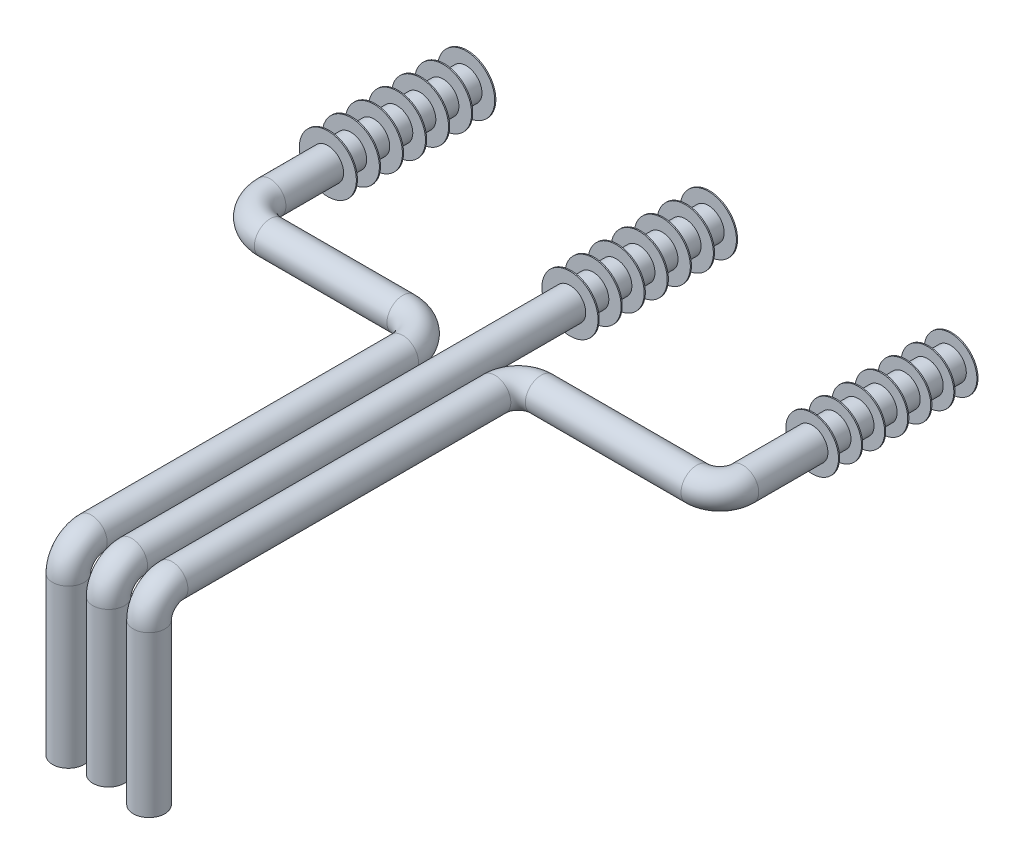
from build123d import *

# Parameters (mm, degrees)
BARRER5_PROFILE_R       = 13.7
BARRER6_PROFILE_R       = 13.7
CROQUIS41_R             = 13.7
CROQUIS62_R             = 22.870183784
CROQUIS62_R_2           = 24.36570856
CROQUIS62_R_3           = 24.738020287
SALIENTE_EXTRUIR1_DEPTH = 1
MATRIZL1_COUNT          = 7
MATRIZL1_PITCH          = 20


with BuildPart() as part:
    # Barrer5: sweep along a curve in space
    with BuildLine() as barrer5_path:
        Line((0, 0, 0), (0, 0, 170))
        ThreePointArc((0, 0, 170), (8.786796564, 0, 191.213203436), (30, 0, 200))
        Line((30, 0, 200), (145.00018, 0, 200))
        ThreePointArc((145.00018, 0, 200), (166.213383436, 0, 208.786796564), (175.00018, 0, 230))
        Line((175.00018, 0, 230), (175.00018, 0, 500))
        ThreePointArc((175.00018, 0, 500), (175.00018, -5.857864376, 514.142135624), (175.00018, -20, 520))
        Line((175.00018, -20, 520), (175.00018, -156.800061359, 520))
    # Barrer5 profile (on start of the path) → Barrer5 (sweep)
    with BuildSketch(Plane.XY):
        Circle(BARRER5_PROFILE_R)
    sweep(path=barrer5_path.line)


with BuildPart() as body_2:
    # Barrer6: sweep along a curve in space
    with BuildLine() as barrer6_path:
        Line((210, 0, 0), (210, 0, 499.997033))
        ThreePointArc((210, 0, 499.997033), (210, -5.857864376, 514.139168624), (210, -20, 519.997033))
        Line((210, -20, 519.997033), (210, -153.425324093, 519.997033))
    # Barrer6 profile (on start of the path) → Barrer6 (sweep)
    with BuildSketch(Plane(origin=(210, 0, 0), x_dir=(1, 0, 0), z_dir=(0, 0, 1))):
        Circle(BARRER6_PROFILE_R)
    sweep(path=barrer6_path.line)


with BuildPart() as body_3:
    # Barrer7: sweep along a curve in space
    with BuildLine() as barrer7_path:
        Line((420, 0, 0), (420, 0, 180))
        ThreePointArc((420, 0, 180), (414.142135624, 0, 194.142135624), (400, 0, 200))
        Line((400, 0, 200), (264.998005, 0, 200))
        ThreePointArc((264.998005, 0, 200), (250.855869376, 0, 205.857864376), (244.998005, 0, 220))
        Line((244.998005, 0, 220), (244.998005, 0, 500))
        ThreePointArc((244.998005, 0, 500), (244.998005, -5.857864376, 514.142135624), (244.998005, -20, 520))
        Line((244.998005, -20, 520), (244.998005, -158.814937218, 520))
    # Croquis41 → Barrer7 (sweep)
    with BuildSketch(Plane(origin=(0, 0, 0), x_dir=(-1, 0, 0), z_dir=(0, 0, -1))):
        with Locations((-420, 0)):
            Circle(CROQUIS41_R)
    sweep(path=barrer7_path.line)

    # Croquis62 → Saliente-Extruir1 (add)
    with BuildSketch(Plane(origin=(0, 0, 0), x_dir=(-1, 0, 0), z_dir=(0, 0, -1))):
        with Locations((-420, 0)):
            Circle(CROQUIS62_R)
        with Locations((-210, 0)):
            Circle(CROQUIS62_R_2)
        Circle(CROQUIS62_R_3)
    saliente_extruir1 = extrude(amount=SALIENTE_EXTRUIR1_DEPTH)


with BuildPart() as saliente_extruir1_piece_1:
    # of the separate pieces the step leaves, piece 1, a body of its own (saliente_extruir1_pieces)
    add(body_3.part.solids().sort_by_distance((397.129816216, 0, 0))[0])


with BuildPart() as saliente_extruir1_piece_2:
    # of the separate pieces the step leaves, piece 2, a body of its own (saliente_extruir1_pieces)
    add(body_3.part.solids().sort_by_distance((-24.738020287, 0, 0))[0])


with BuildPart() as saliente_extruir1_piece_3:
    # of the separate pieces the step leaves, piece 3, a body of its own (saliente_extruir1_pieces)
    add(body_3.part.solids().sort_by_distance((185.63429144, 0, 0))[0])


with BuildPart() as part_1:
    add(part.part)

    add(body_2.part)  # MatrizL1 merges body 2

    add(saliente_extruir1_piece_1.part)  # MatrizL1 merges Saliente-Extruir1 piece 1
    # MatrizL1: Saliente-Extruir1 ×7
    with Locations(*[(0, 0, i * MATRIZL1_PITCH) for i in range(1, MATRIZL1_COUNT)]):
        add(saliente_extruir1)


solid = Compound([saliente_extruir1_piece_2.part, saliente_extruir1_piece_3.part, part_1.part])
